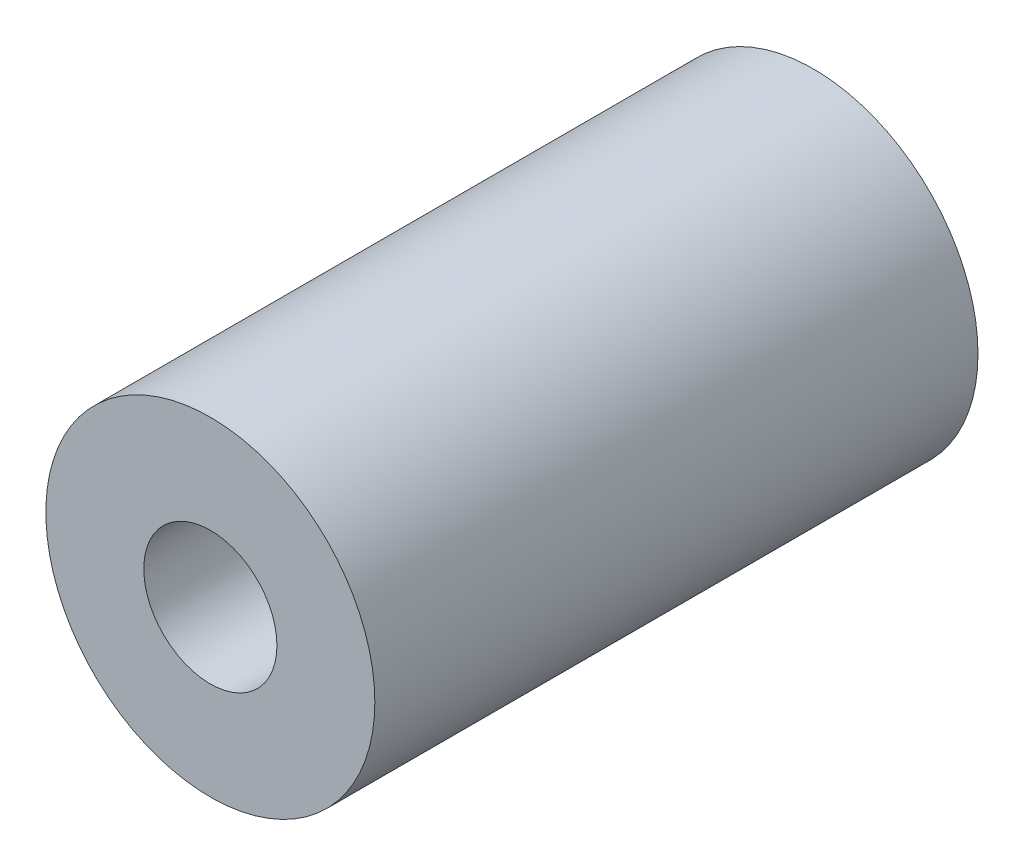
from build123d import *

# Parameters (mm, degrees)
SKETCH1_W           = 3.125
SKETCH1_H           = 3.75
SKETCH2_R           = 5.25
SKETCH2_R_2         = 2.125
BOSS_EXTRUDE1_DEPTH = 16
SKETCH3_R           = 5.25
SKETCH3_R_2         = 3
CUT_EXTRUDE1_DEPTH  = 0.5


with BuildPart() as part:
    # Sketch1 → Revolve1 (revolve)
    with BuildSketch(Plane(origin=(0, 0, 0), x_dir=(1, 0, 0), z_dir=(0, 1, 0))):
        with Locations((3.6875, -1.875)):
            Rectangle(SKETCH1_W, SKETCH1_H)
    revolve(axis=Axis((0, 0, 0), (0, 0, 1)))

    # Sketch2 → Boss-Extrude1 (add)
    with BuildSketch(Plane.XY.offset(3.75)):
        Circle(SKETCH2_R)
        Circle(SKETCH2_R_2, mode=Mode.SUBTRACT)
    extrude(amount=BOSS_EXTRUDE1_DEPTH)

    # Sketch3 → Cut-Extrude1 (cut)
    with BuildSketch(Plane(origin=(0, 0, 0), x_dir=(-1, 0, 0), z_dir=(0, 0, -1))):
        Circle(SKETCH3_R)
        Circle(SKETCH3_R_2, mode=Mode.SUBTRACT)
    extrude(amount=-CUT_EXTRUDE1_DEPTH, mode=Mode.SUBTRACT)


solid = part.part
